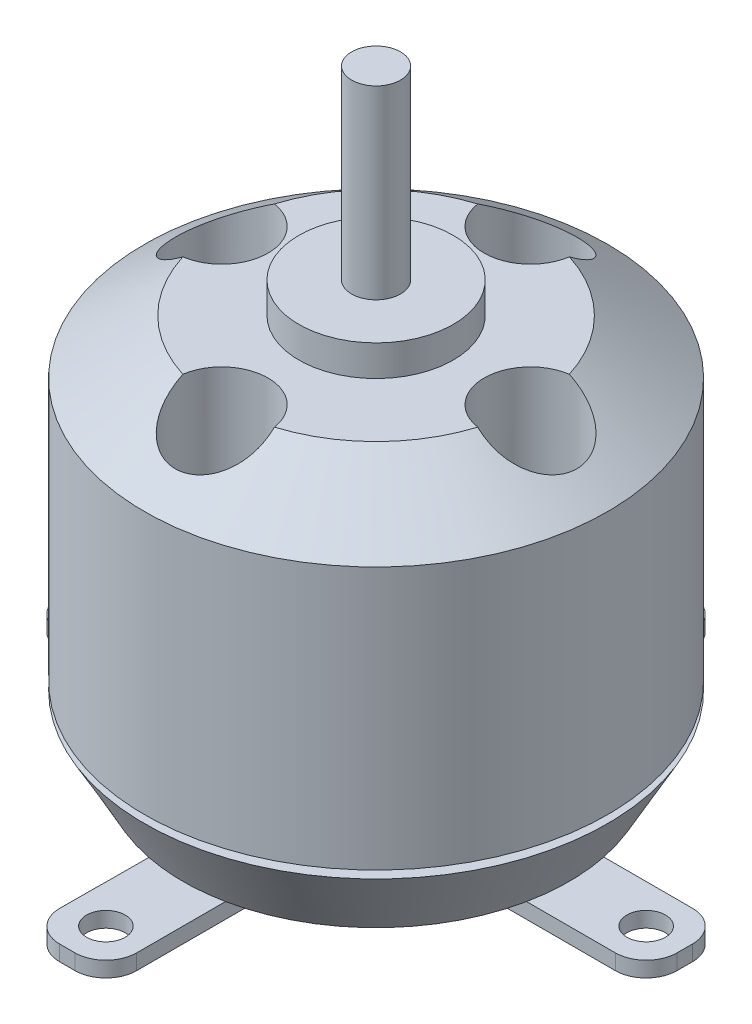
from build123d import *

# Parameters (mm, degrees)
SKETCH4_R                  = 3
MOTOR_COOLING_SYSTEM_DEPTH = 6
SKETCH6_R                  = 3
MOTOR_BASE_HOLDER_DEPTH    = 1
SKETCH9_R                  = 1.25
SKETCH9_R_2                = 1.5
SCREWS_CUT_DEPTH           = 2


with BuildPart() as part:
    # Sketch1 → Electric motor body (revolve)
    with BuildSketch(Plane.XY):
        Polygon((0, 0), (1.585, 0), (1.585, 1), (12.5, 1), (15, 5.5), (1.585, 5.5), (1.585, 6), (15, 6), (15, 23), (10, 26.5), (5, 26.5), (5, 28.5), (1.585, 28.5), (1.585, 40.5), (0, 40.5), align=None)
    revolve(axis=Axis((0, 0, 0), (0, 1, 0)))

    # Sketch4 → motor cooling system (cut)
    with BuildSketch(Plane(origin=(0, 26.5, 0), x_dir=(1, 0, 0), z_dir=(0, 1, 0))):
        with Locations((0, -10)):
            Circle(SKETCH4_R)
        with Locations((-10, 0)):
            Circle(SKETCH4_R)
        with Locations((10, 0)):
            Circle(SKETCH4_R)
        with Locations((0, 10)):
            Circle(SKETCH4_R)
    extrude(amount=-MOTOR_COOLING_SYSTEM_DEPTH, mode=Mode.SUBTRACT)

    # Sketch6 → Motor base holder (add)
    with BuildSketch(Plane.XZ.offset(-1)):
        with BuildLine():
            Line((19.994606566, -0.5), (19.994606566, 0.5))
            ThreePointArc((19.994606566, 0.5), (19.408820128, 1.914213562), (17.994606566, 2.5))
            Line((17.994606566, 2.5), (9.994606566, 2.5))
            ThreePointArc((9.994606566, 2.5), (4.691305707, 4.696699141), (2.494606566, 10))
            Line((2.494606566, 10), (2.494606566, 18))
            ThreePointArc((2.494606566, 18), (1.908820128, 19.414213562), (0.494606566, 20))
            Line((0.494606566, 20), (-0.494606566, 20))
            ThreePointArc((-0.494606566, 20), (-1.912618477, 19.410404985), (-2.494577633, 17.989242221))
            Line((-2.494577633, 17.989242221), (-2.451820757, 10.040341672))
            ThreePointArc((-2.451820757, 10.040341672), (-4.634167594, 4.710981307), (-9.951712259, 2.5))
            Line((-9.951712259, 2.5), (-18.005393434, 2.5))
            ThreePointArc((-18.005393434, 2.5), (-19.419606996, 1.914213562), (-20.005393434, 0.5))
            Line((-20.005393434, 0.5), (-20.005393434, -0.5))
            ThreePointArc((-20.005393434, -0.5), (-19.419606996, -1.914213562), (-18.005393434, -2.5))
            Line((-18.005393434, -2.5), (-9.994606566, -2.5))
            ThreePointArc((-9.994606566, -2.5), (-4.691305707, -4.696699141), (-2.494606566, -10))
            Line((-2.494606566, -10), (-2.494606566, -18))
            ThreePointArc((-2.494606566, -18), (-1.908820128, -19.414213562), (-0.494606566, -20))
            Line((-0.494606566, -20), (0.494606566, -20))
            ThreePointArc((0.494606566, -20), (1.908820128, -19.414213562), (2.494606566, -18))
            Line((2.494606566, -18), (2.494606566, -10))
            ThreePointArc((2.494606566, -10), (4.691305707, -4.696699141), (9.994606566, -2.5))
            Line((9.994606566, -2.5), (17.994606566, -2.5))
            ThreePointArc((17.994606566, -2.5), (19.408820128, -1.914213562), (19.994606566, -0.5))
        make_face()
        Circle(SKETCH6_R, mode=Mode.SUBTRACT)
    extrude(amount=MOTOR_BASE_HOLDER_DEPTH)

    # Sketch9 → Screws cut (cut)
    with BuildSketch(Plane.XZ):
        with Locations((-17.505393434, 0)):
            Circle(SKETCH9_R)
        with Locations((17.494606566, 0)):
            Circle(SKETCH9_R)
        with Locations((0, -17.5)):
            Circle(SKETCH9_R)
        with Locations((0, 17.5)):
            Circle(SKETCH9_R)
        with Locations((7, 0)):
            Circle(SKETCH9_R_2)
        with Locations((0, -7)):
            Circle(SKETCH9_R_2)
        with Locations((-7, 0)):
            Circle(SKETCH9_R_2)
        with Locations((0, 7)):
            Circle(SKETCH9_R_2)
    extrude(amount=-SCREWS_CUT_DEPTH, mode=Mode.SUBTRACT)


solid = part.part
